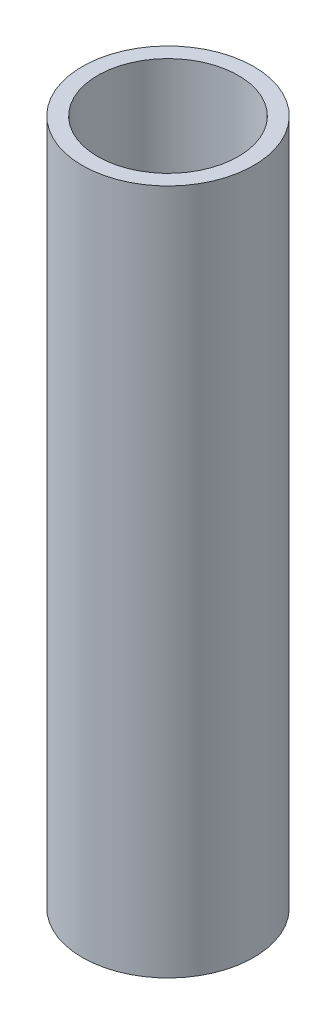
from build123d import *

# Parameters (mm, degrees)
SKETCH1_R           = 12.7
SKETCH1_R_2         = 10.414
BOSS_EXTRUDE1_DEPTH = 101.6


with BuildPart() as part:
    # Sketch1 → Boss-Extrude1 (new body)
    with BuildSketch(Plane(origin=(0, 0, 0), x_dir=(1, 0, 0), z_dir=(0, 1, 0))):
        Circle(SKETCH1_R)
        Circle(SKETCH1_R_2, mode=Mode.SUBTRACT)
    extrude(amount=BOSS_EXTRUDE1_DEPTH)


solid = part.part
